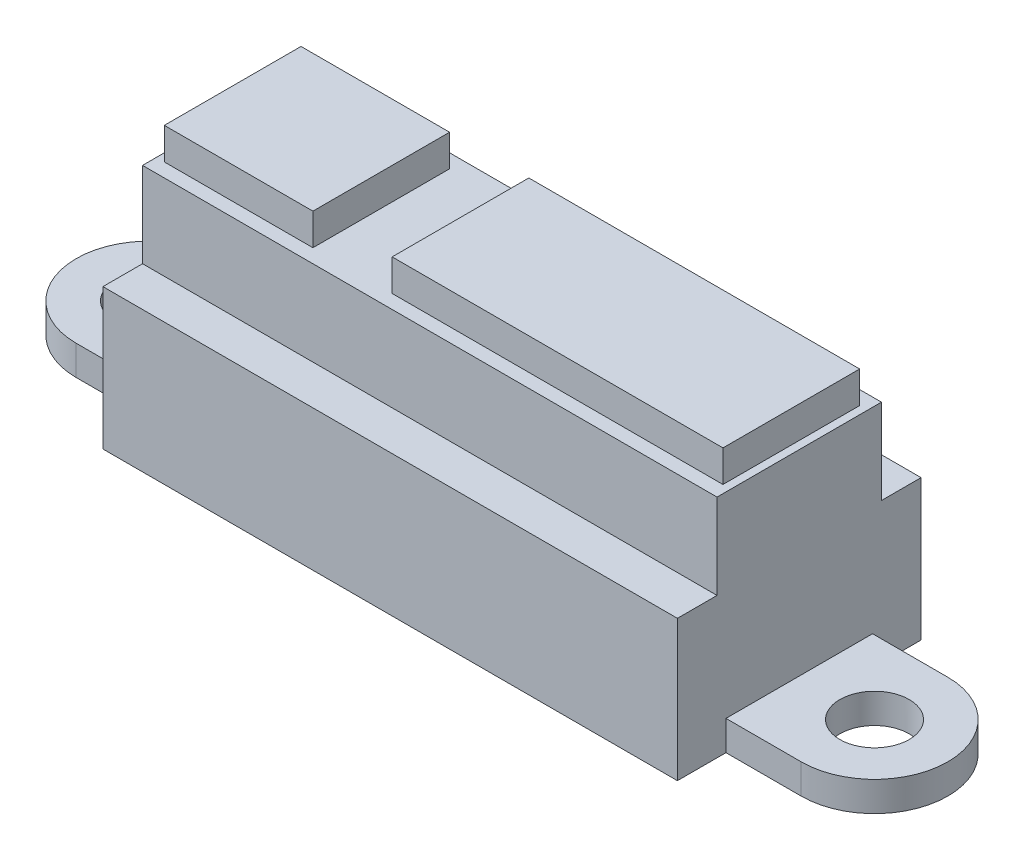
from build123d import *

# Parameters (mm, degrees)
RESSALTO_EXTRUS_O1_DEPTH = 12.3
ESBO_O2_R                = 1.75
CORTE_EXTRUS_O1_DEPTH    = 22.3
CORTE_EXTRUS_O2_DEPTH    = 32.3


with BuildPart() as part:
    # Esboço1 → Ressalto-extrusão1 (new body)
    with BuildSketch(Plane.XY):
        Polygon((-14.1, 13), (-14.1, 11.4), (-14.5, 11.4), (-14.5, 1.5), (-22, 1.5), (-22, 0), (-14.5, 0), (14.5, 0), (22, 0), (22, 1.5), (14.5, 1.5), (14.5, 11.4), (14.1, 11.4), (14.1, 13), (-2.6, 13), (-2.6, 11.4), (-6.6, 11.4), (-6.6, 13), align=None)
    extrude(amount=RESSALTO_EXTRUS_O1_DEPTH)

    # Esboço2 → Corte-extrusão1 (cut)
    with BuildSketch(Plane(origin=(0, 13, 0), x_dir=(1, 0, 0), z_dir=(0, 1, 0))):
        with BuildLine():
            ThreePointArc((-18.3, -9.85), (-20.91629509, -8.76629509), (-22, -6.15))
            Line((-22, -6.15), (-22, -12.3))
            Line((-22, -12.3), (-14.5, -12.3))
            Line((-14.5, -12.3), (-14.5, -9.85))
            Line((-14.5, -9.85), (-18.3, -9.85))
        make_face()
        with BuildLine():
            ThreePointArc((-22, -6.15), (-20.91629509, -3.53370491), (-18.3, -2.45))
            Line((-18.3, -2.45), (-14.5, -2.45))
            Line((-14.5, -2.45), (-14.5, 0))
            Line((-14.5, 0), (-22, 0))
            Line((-22, 0), (-22, -6.15))
        make_face()
        with BuildLine():
            ThreePointArc((18.3, -2.45), (20.91629509, -3.53370491), (22, -6.15))
            Line((22, -6.15), (22, 0))
            Line((22, 0), (14.5, 0))
            Line((14.5, 0), (14.5, -2.45))
            Line((14.5, -2.45), (18.3, -2.45))
        make_face()
        with BuildLine():
            Line((14.5, -12.3), (22, -12.3))
            Line((22, -12.3), (22, -6.15))
            ThreePointArc((22, -6.15), (20.91629509, -8.76629509), (18.3, -9.85))
            Line((18.3, -9.85), (14.5, -9.85))
            Line((14.5, -9.85), (14.5, -12.3))
        make_face()
        with Locations((-18.3, -6.15)):
            Circle(ESBO_O2_R)
        with Locations((18.3, -6.15)):
            Circle(ESBO_O2_R)
    extrude(amount=-CORTE_EXTRUS_O1_DEPTH, mode=Mode.SUBTRACT)

    # Esboço3 → Corte-extrusão2 (cut)
    with BuildSketch(Plane.ZY.offset(14.5)):
        Polygon((2.7, 13), (2.7, 11.4), (2, 11.4), (2, 7.1), (0, 7.1), (0, 13), align=None)
        Polygon((12.3, 13), (12.3, 7.1), (10.3, 7.1), (10.3, 11.4), (9.6, 11.4), (9.6, 13), align=None)
    extrude(amount=-CORTE_EXTRUS_O2_DEPTH, mode=Mode.SUBTRACT)


solid = part.part
